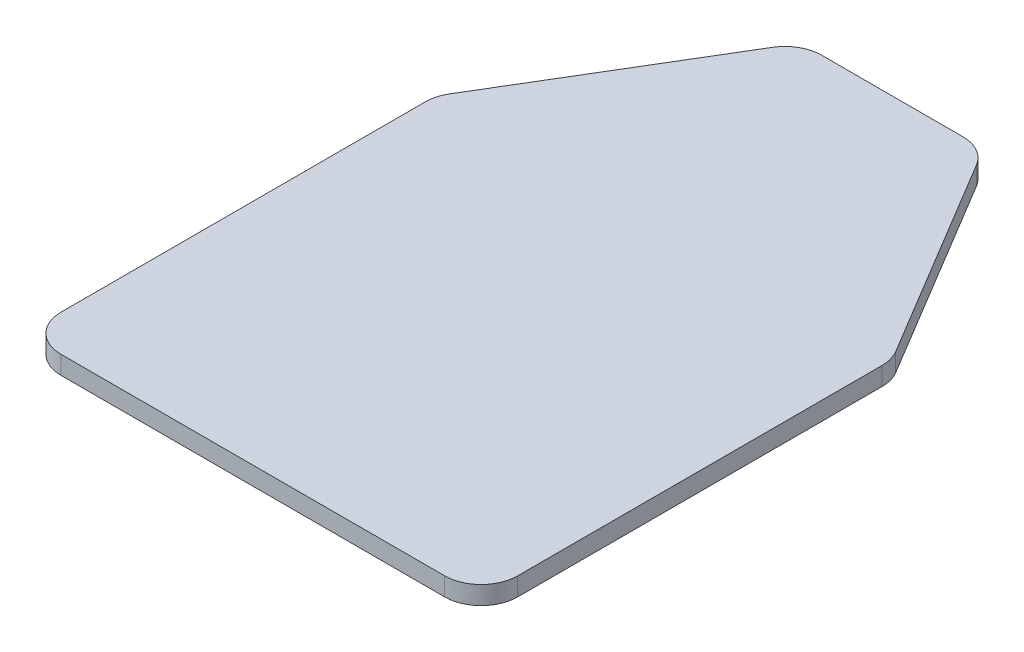
from build123d import *

# Parameters (mm, degrees)
EXTRUDE_1_DEPTH = 20


with BuildPart() as part:
    # Эскиз1 → Бобышка-Вытянуть1 (new body)
    with BuildSketch(Plane(origin=(0, 0, 0), x_dir=(1, 0, 0), z_dir=(0, 1, 0))):
        with BuildLine():
            Line((210, 0), (-210, 0))
            ThreePointArc((-210, 0), (-238.284271247, 11.715728753), (-250, 40))
            Line((-250, 40), (-250, 438.920641402))
            ThreePointArc((-250, 438.920641402), (-248.548597128, 449.597984678), (-244.299717029, 459.500471619))
            Line((-244.299717029, 459.500471619), (-111.65210187, 680.579830217))
            ThreePointArc((-111.65210187, 680.579830217), (-97.060337441, 694.80799627), (-77.352384841, 700))
            Line((-77.352384841, 700), (77.352384841, 700))
            ThreePointArc((77.352384841, 700), (97.060337441, 694.80799627), (111.65210187, 680.579830217))
            Line((111.65210187, 680.579830217), (244.299717029, 459.500471619))
            ThreePointArc((244.299717029, 459.500471619), (248.548597128, 449.597984678), (250, 438.920641402))
            Line((250, 438.920641402), (250, 40))
            ThreePointArc((250, 40), (238.284271247, 11.715728753), (210, 0))
        make_face()
    extrude(amount=EXTRUDE_1_DEPTH)


solid = part.part
